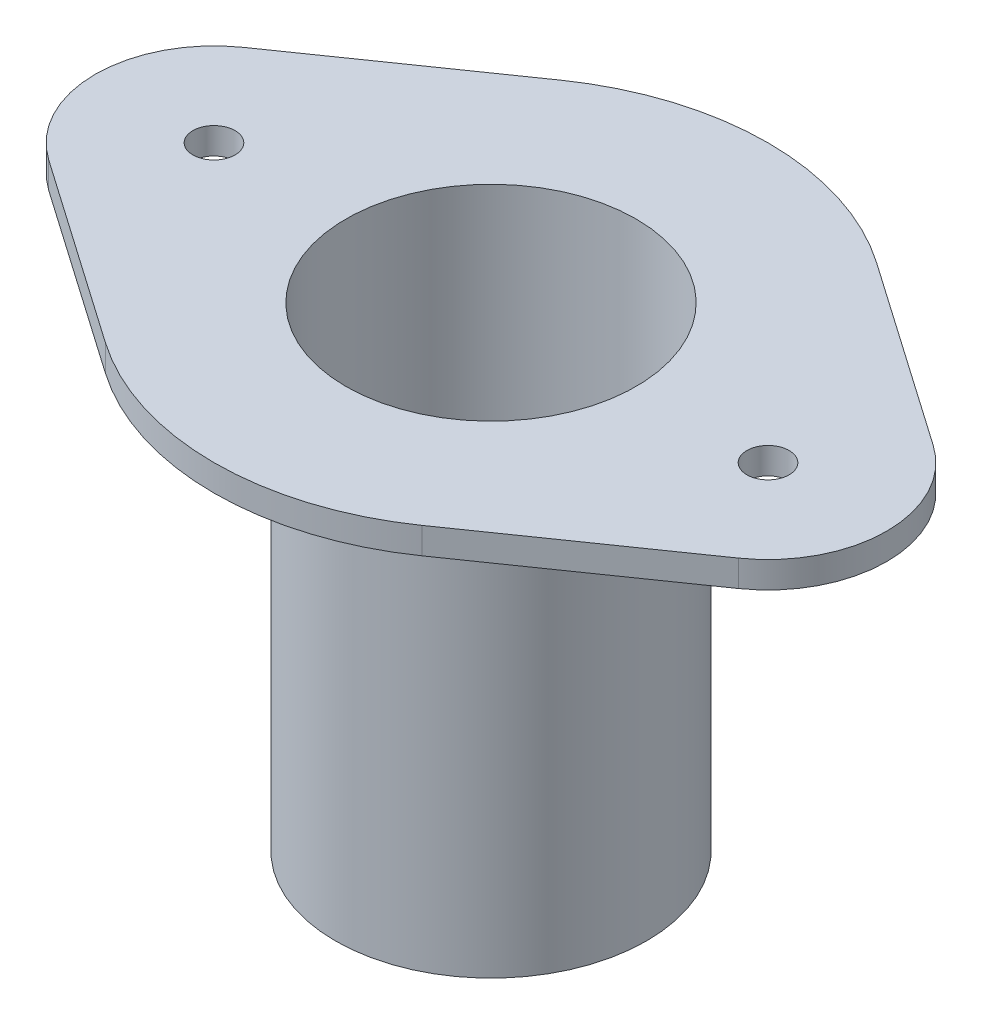
from build123d import *

# Parameters (mm, degrees)
SKETCH1_R           = 29.5
SKETCH1_R_2         = 27.5
BOSS_EXTRUDE1_DEPTH = 85
SKETCH2_R           = 4
SKETCH2_R_2         = 27.5
BOSS_EXTRUDE2_DEPTH = 5


with BuildPart() as part:
    # Sketch1 → Boss-Extrude1 (new body)
    with BuildSketch(Plane(origin=(0, 0, 0), x_dir=(1, 0, 0), z_dir=(0, 1, 0))):
        Circle(SKETCH1_R)
        Circle(SKETCH1_R_2, mode=Mode.SUBTRACT)
    extrude(amount=BOSS_EXTRUDE1_DEPTH)

    # Sketch2 → Boss-Extrude2 (add)
    with BuildSketch(Plane(origin=(0, 85, 0), x_dir=(1, 0, 0), z_dir=(0, 1, 0))):
        with BuildLine():
            Line((30, 43.084219849), (65.357142857, 18.46466565))
            ThreePointArc((65.357142857, 18.46466565), (75, 0), (65.357142857, -18.46466565))
            Line((65.357142857, -18.46466565), (30, -43.084219849))
            ThreePointArc((30, -43.084219849), (0, -52.5), (-30, -43.084219849))
            Line((-30, -43.084219849), (-65.357142857, -18.46466565))
            ThreePointArc((-65.357142857, -18.46466565), (-75, 0), (-65.357142857, 18.46466565))
            Line((-65.357142857, 18.46466565), (-30, 43.084219849))
            ThreePointArc((-30, 43.084219849), (0, 52.5), (30, 43.084219849))
        make_face()
        with Locations((52.5, 0)):
            Circle(SKETCH2_R, mode=Mode.SUBTRACT)
        with Locations((-52.5, 0)):
            Circle(SKETCH2_R, mode=Mode.SUBTRACT)
        Circle(SKETCH2_R_2, mode=Mode.SUBTRACT)
    extrude(amount=BOSS_EXTRUDE2_DEPTH)


solid = part.part
